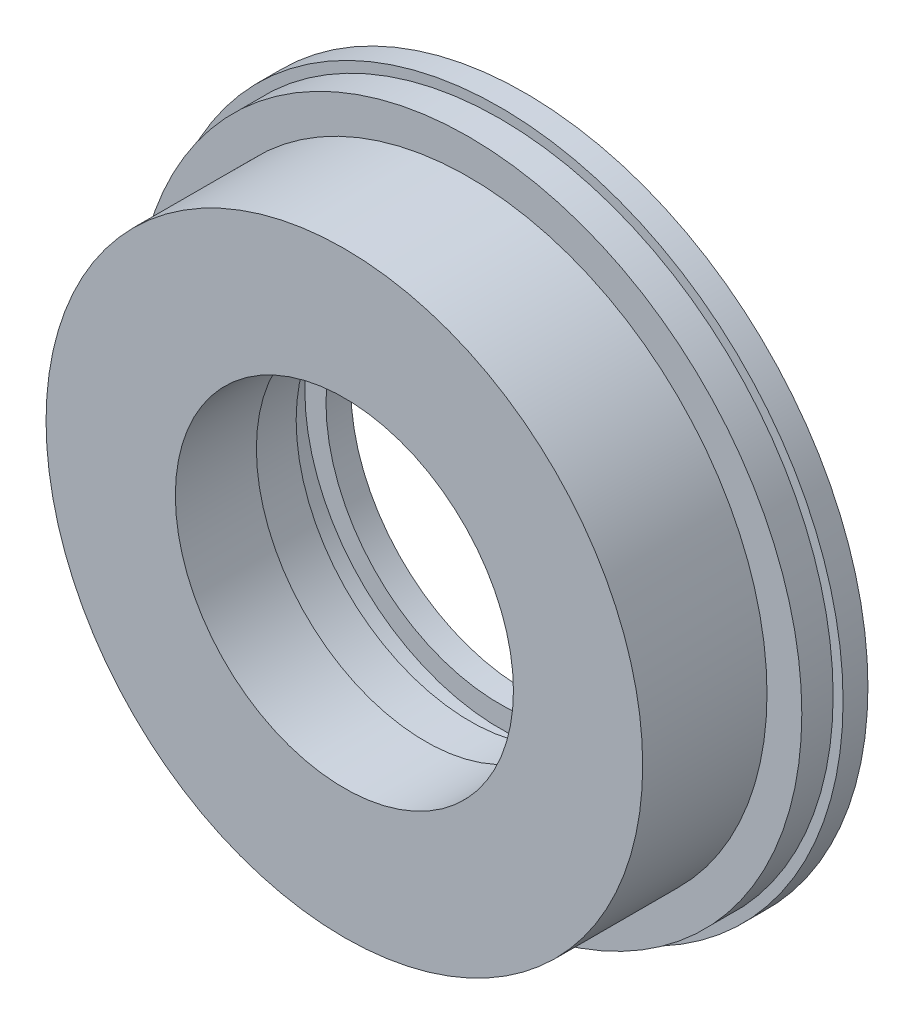
from build123d import *

# Parameters (mm, degrees)
SKETCH1_R           = 70
BOSS_EXTRUDE1_DEPTH = 40
SKETCH3_W           = 14
SKETCH3_H           = 32.4
SKETCH5_W           = 26.233930481
SKETCH5_H           = 6
SKETCH6_W           = 149.593137009
SKETCH6_H           = 50.047703926
CUT_EXTRUDE1_DEPTH  = 86


with BuildPart() as part:
    # Sketch1 → Boss-Extrude1 (new body, symmetric)
    with BuildSketch(Plane.XY):
        Circle(SKETCH1_R)
    extrude(amount=BOSS_EXTRUDE1_DEPTH, both=True)

    # Sketch2 → Cut-Revolve1 (revolve, cut)
    with BuildSketch(Plane(origin=(0, 0, 0), x_dir=(1, 0, 0), z_dir=(0, 1, 0))):
        Polygon((-69, 40), (-69, 35), (-67, 35), (-67, 28.7), (-60, 28.7), (-60, 3.7), (-67, 3.7), (-67, -2.6), (-69, -2.6), (-69, -44.705491592), (-73.643536697, -44.705491592), (-73.643536697, 40), align=None)
    revolve(axis=Axis((0, 0, 0), (0, 0, -1)), mode=Mode.SUBTRACT)

    # Sketch3 → Cut-Revolve2 (revolve, cut)
    with BuildSketch(Plane(origin=(0, 0, 0), x_dir=(1, 0, 0), z_dir=(0, 1, 0))):
        with Locations((-62, -23.8)):
            Rectangle(SKETCH3_W, SKETCH3_H)
    revolve(axis=Axis((0, 0, 0), (0, 0, 1)), mode=Mode.SUBTRACT)

    # Sketch4 → Cut-Revolve3 (revolve, cut)
    with BuildSketch(Plane(origin=(0, 0, 0), x_dir=(1, 0, 0), z_dir=(0, 1, 0))):
        Polygon((0, 42.623044552), (-35, 42.623044552), (-35, 20), (-34, 20), (-34, -40), (0, -40), align=None)
    revolve(axis=Axis((0, 0, 0), (0, 0, -1)), mode=Mode.SUBTRACT)

    # Sketch5 → Cut-Revolve4 (revolve, cut)
    with BuildSketch(Plane(origin=(0, 0, 0), x_dir=(1, 0, 0), z_dir=(0, 1, 0))):
        with Locations((-26.133034759, 32)):
            Rectangle(SKETCH5_W, SKETCH5_H)
    revolve(axis=Axis((0, 0, 0), (0, 0, -1)), mode=Mode.SUBTRACT)

    # Sketch6 → Cut-Extrude1 (cut, symmetric)
    with BuildSketch(Plane(origin=(0, 0, 0), x_dir=(1, 0, 0), z_dir=(0, 1, 0))):
        with Locations((-0.733299692, -21.323851963)):
            Rectangle(SKETCH6_W, SKETCH6_H)
    extrude(amount=CUT_EXTRUDE1_DEPTH, both=True, mode=Mode.SUBTRACT)


solid = part.part
